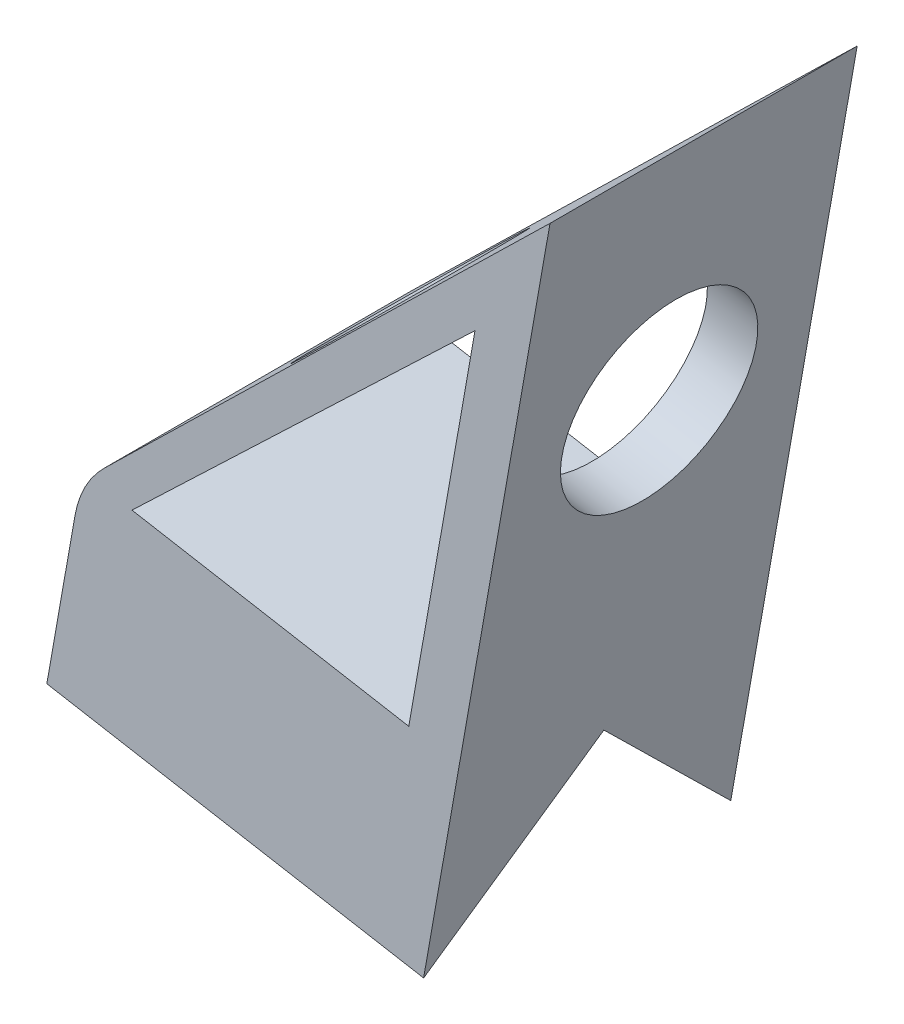
from build123d import *

# Parameters (mm, degrees)
BOSS_EXTRUDE1_DEPTH   = 76.2
CUT_EXTRUDE3_DEPTH    = 77.2
CUT_EXTRUDE4_DEPTH    = 77.2
CUT_EXTRUDE5_DEPTH    = 126.785464248
SLANTED_CIRCLE_REACH  = 129.265
SKETCH10_R            = 24.13
BACK_CIRCLE_CUT_REACH = 124.924
SKETCH11_R            = 24.13
FILLET2_R             = 25.4


with BuildPart() as part:
    # Sketch2 → Boss-Extrude1 (new body)
    with BuildSketch(Plane.XY):
        Polygon((0, 203.2), (-31.35093717, 25.4), (-159.146418514, 47.933791374), align=None)
    extrude(amount=-BOSS_EXTRUDE1_DEPTH)

    # Sketch6 → Cut-Extrude3 (cut, through all)
    with BuildSketch(Plane.XY):
        Polygon((-18.598164113, 170.860955123), (-35.036668208, 77.633565709), (-103.699217462, 89.740625707), align=None)
    extrude(amount=-CUT_EXTRUDE3_DEPTH, mode=Mode.SUBTRACT)

    # Sketch8 → Cut-Extrude4 (cut, through all)
    with BuildSketch(Plane.XY):
        Polygon((-124.819846836, 41.881090632), (-116.398812065, 89.639152029), (-159.146418514, 47.933791374), align=None)
    extrude(amount=-CUT_EXTRUDE4_DEPTH, mode=Mode.SUBTRACT)

    # Sketch9 → Cut-Extrude5 (cut, through all)
    with BuildSketch(Plane(origin=(-128.218156228, 22.60832036, 0), x_dir=(0, 0, 1), z_dir=(-0.984807753, 0.173648178, 0))):
        Polygon((-76.2, 19.570083819), (-38.1, 57.670083819), (0, 19.570083819), align=None)
    extrude(amount=-CUT_EXTRUDE5_DEPTH, mode=Mode.SUBTRACT)

    # Sketch10 → Slanted Circle (cut, up to next)
    with BuildSketch(Plane(origin=(-101.569056599, 104.107337538, 0), x_dir=(0.715778778, 0.698327101, 0), z_dir=(-0.698327101, 0.715778778, 0)), mode=Mode.PRIVATE) as slanted_circle_sk1:
        with Locations((40.241649701, 38.1)):
            Circle(SKETCH10_R)
    slanted_circle_tool1 = extrude(slanted_circle_sk1.sketch, amount=-SLANTED_CIRCLE_REACH, mode=Mode.PRIVATE) & part.part
    add(slanted_circle_tool1.solids().sort_by_distance((-72.764938, 132.209172, -38.1))[0], mode=Mode.SUBTRACT)

    # Sketch11 → Back Circle Cut (cut, up to next)
    with BuildSketch(Plane(origin=(-34.749246562, 6.127229728, 0), x_dir=(0, 0, -1), z_dir=(0.984807753, -0.173648178, 0)), mode=Mode.PRIVATE) as back_circle_cut_sk1:
        with Locations((38.1, 136.612935412)):
            Circle(SKETCH11_R)
    back_circle_cut_tool1 = extrude(back_circle_cut_sk1.sketch, amount=-BACK_CIRCLE_CUT_REACH, mode=Mode.PRIVATE) & part.part
    add(back_circle_cut_tool1.solids().sort_by_distance((-11.026659, 140.664708, -38.1))[0], mode=Mode.SUBTRACT)

    # Fillet2
    fillet2_edges = [part.edges().sort_by_distance(p)[0] for p in [
        (-116.398812065, 89.639152029, -38.1),
    ]]
    fillet(fillet2_edges, radius=FILLET2_R)


solid = part.part
